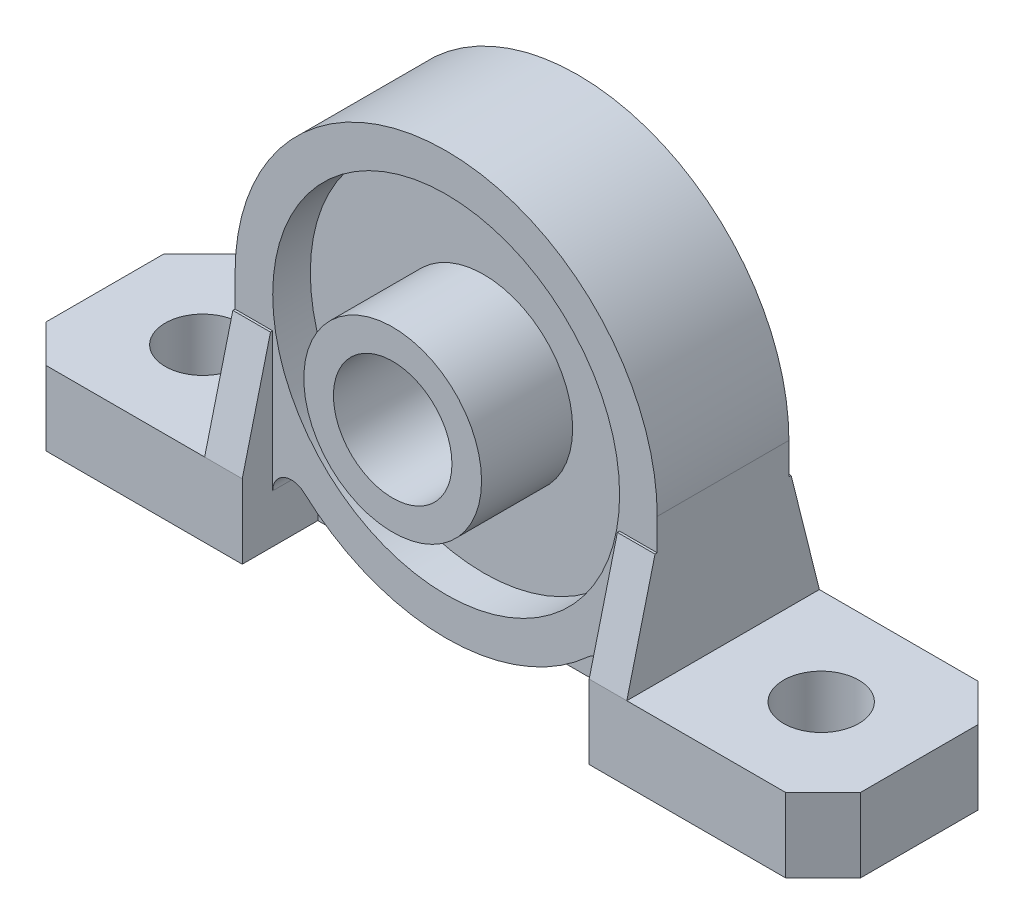
from build123d import *

# Parameters (mm, degrees)
SKETCH1_W                = 55
SKETCH1_H                = 13
BOSS_EXTRUDE1_DEPTH      = 29
CUT_EXTRUDE1_DEPTH       = 14
SKETCH3_OUTSIDE_W        = 69.704
SKETCH3_OUTSIDE_H        = 27.704
SKETCH3_OUTSIDE_W_2      = 28.5
SKETCH3_OUTSIDE_H_2      = 8.89
CUT_EXTRUDE2_DEPTH       = 25
SKETCH5_W                = 2.54
SKETCH5_H                = 7.62
BOSS_EXTRUDE2_DEPTH      = 6.5
BOSS_EXTRUDE2_DEPTH_BACK = 6.5
CHAMFER1_SIZE            = 1.905
CHAMFER1_SIZE2           = 7.62
CHAMFER1_PART_2_SIZE     = 1.905
CHAMFER1_PART_2_SIZE2    = 7.62
CHAMFER2_SIZE            = 7.62
CHAMFER2_SIZE2           = 1.905
CUT_EXTRUDE3_START       = -1.397
CUT_EXTRUDE3_DEPTH       = 6.1030001
CUT_EXTRUDE4_START       = -4.445
SKETCH7_W                = 23.42
SKETCH7_H                = 12.62
CUT_EXTRUDE4_DEPTH       = 3.0550001
SKETCH8_R                = 4
CUT_EXTRUDE5_DEPTH       = 7.5000001
CUT_EXTRUDE5_DEPTH_BACK  = 7.5000001
SKETCH9_R                = 11.71
CUT_EXTRUDE6_DEPTH       = 2.54
CHAMFER3_SIZE            = 2.54
SKETCH10_R               = 2.54
CUT_EXTRUDE7_DEPTH       = 6.0000001
SKETCH11_R               = 6
SKETCH11_R_2             = 4
BOSS_EXTRUDE3_DEPTH      = 6.15


with BuildPart() as part:
    # Sketch1 → Boss-Extrude1 (new body)
    with BuildSketch(Plane(origin=(0, 0, 0), x_dir=(1, 0, 0), z_dir=(0, 1, 0))):
        Rectangle(SKETCH1_W, SKETCH1_H)
    extrude(amount=BOSS_EXTRUDE1_DEPTH)

    # Sketch2 → Cut-Extrude1 (cut, through all)
    with BuildSketch(Plane.XY.offset(6.5)):
        with BuildLine():
            ThreePointArc((-14.25, 14.75), (-10.076271632, 24.826271632), (0, 29))
            Line((0, 29), (-27.5, 29))
            Line((-27.5, 29), (-27.5, 5))
            Line((-27.5, 5), (-14.25, 5))
            Line((-14.25, 5), (-14.25, 14.75))
        make_face()
        with BuildLine():
            Line((14.25, 5), (27.5, 5))
            Line((27.5, 5), (27.5, 29))
            Line((27.5, 29), (0, 29))
            ThreePointArc((0, 29), (10.076271632, 24.826271632), (14.25, 14.75))
            Line((14.25, 14.75), (14.25, 5))
        make_face()
    extrude(amount=-CUT_EXTRUDE1_DEPTH, mode=Mode.SUBTRACT)

    # Sketch3 outside → Cut-Extrude2 (cut, through all)
    with BuildSketch(Plane(origin=(0, 5, 0), x_dir=(1, 0, 0), z_dir=(0, 1, 0))):
        Rectangle(SKETCH3_OUTSIDE_W, SKETCH3_OUTSIDE_H)
        Rectangle(SKETCH3_OUTSIDE_W_2, SKETCH3_OUTSIDE_H_2, mode=Mode.SUBTRACT)
    extrude(amount=CUT_EXTRUDE2_DEPTH, mode=Mode.SUBTRACT)

    # Sketch5 → Boss-Extrude2 (add, two sides)
    with BuildSketch(Plane.XY) as boss_extrude2_sk:
        with Locations((12.98, 8.81)):
            Rectangle(SKETCH5_W, SKETCH5_H)
        with Locations((-12.98, 8.81)):
            Rectangle(SKETCH5_W, SKETCH5_H)
    extrude(amount=BOSS_EXTRUDE2_DEPTH)
    extrude(boss_extrude2_sk.sketch, amount=-BOSS_EXTRUDE2_DEPTH_BACK)

    # Chamfer1
    chamfer1_edges = [part.edges().sort_by_distance(p)[0] for p in [
        (12.98, 12.62, 6.5),
    ]]
    chamfer1_side = [part.faces().sort_by_distance(p)[0] for p in [
        (12.98, 12.62, 5.4725),
    ]]
    chamfer(chamfer1_edges, length=CHAMFER1_SIZE, length2=CHAMFER1_SIZE2, reference=chamfer1_side[0])

    # Chamfer1 part 2
    chamfer1_part_2_edges = [part.edges().sort_by_distance(p)[0] for p in [
        (-12.98, 12.62, 6.5),
    ]]
    chamfer1_part_2_side = [part.faces().sort_by_distance(p)[0] for p in [
        (-12.98, 12.62, 5.4725),
    ]]
    chamfer(chamfer1_part_2_edges, length=CHAMFER1_PART_2_SIZE, length2=CHAMFER1_PART_2_SIZE2, reference=chamfer1_part_2_side[0])

    # Chamfer2
    chamfer2_edges = [part.edges().sort_by_distance(p)[0] for p in [
        (-12.98, 12.62, -6.5),
        (12.98, 12.62, -6.5),
    ]]
    chamfer2_side = [part.faces().sort_by_distance(p)[0] for p in [
        (0, 3.27861046, -6.5),
    ]]
    chamfer(chamfer2_edges, length=CHAMFER2_SIZE, length2=CHAMFER2_SIZE2, reference=chamfer2_side[0])

    # Sketch6 → Cut-Extrude3 (cut, through all)
    with BuildSketch(Plane.XY.offset(CUT_EXTRUDE3_START)):
        with BuildLine():
            Line((11.71, 3.26623755), (11.71, 0))
            Line((11.71, 0), (-11.71, 0))
            Line((-11.71, 0), (-11.71, 3.26623755))
            ThreePointArc((-11.71, 3.26623755), (-10.953777074, 4.427673351), (-9.585695876, 4.205952648))
            ThreePointArc((-9.585695876, 4.205952648), (0, 0.5), (9.585695876, 4.205952648))
            ThreePointArc((9.585695876, 4.205952648), (10.953777074, 4.427673351), (11.71, 3.26623755))
        make_face()
    cut_extrude3 = extrude(amount=-CUT_EXTRUDE3_DEPTH, mode=Mode.SUBTRACT)

    # Sketch7 → Cut-Extrude4 (cut, through all)
    with BuildSketch(Plane.XY.offset(CUT_EXTRUDE4_START)):
        with Locations((0, 6.31)):
            Rectangle(SKETCH7_W, SKETCH7_H)
    cut_extrude4 = extrude(amount=-CUT_EXTRUDE4_DEPTH, mode=Mode.SUBTRACT)

    # Sketch8 → Cut-Extrude5 (cut, two sides)
    with BuildSketch(Plane.XY) as cut_extrude5_sk:
        with Locations((0, 14.5)):
            Circle(SKETCH8_R)
    extrude(amount=CUT_EXTRUDE5_DEPTH, mode=Mode.SUBTRACT)
    extrude(cut_extrude5_sk.sketch, amount=-CUT_EXTRUDE5_DEPTH_BACK, mode=Mode.SUBTRACT)

    # Sketch9 → Cut-Extrude6 (cut)
    with BuildSketch(Plane(origin=(0, 0, -4.445), x_dir=(-1, 0, 0), z_dir=(0, 0, -1))):
        with Locations((0, 14.75)):
            Circle(SKETCH9_R)
    cut_extrude6 = extrude(amount=-CUT_EXTRUDE6_DEPTH, mode=Mode.SUBTRACT)

    # Mirror1: Cut-Extrude3, Cut-Extrude4, Cut-Extrude6 across plane
    add(cut_extrude3.mirror(Plane.XY), mode=Mode.SUBTRACT)
    add(cut_extrude4.mirror(Plane.XY), mode=Mode.SUBTRACT)
    add(cut_extrude6.mirror(Plane.XY), mode=Mode.SUBTRACT)

    # Chamfer3
    chamfer3_edges = [part.edges().sort_by_distance(p)[0] for p in [
        (-27.5, 2.5, 6.5),
        (-27.5, 2.5, -6.5),
        (27.5, 2.5, 6.5),
        (27.5, 2.5, -6.5),
    ]]
    chamfer(chamfer3_edges, length=CHAMFER3_SIZE)

    # Sketch10 → Cut-Extrude7 (cut, through all)
    with BuildSketch(Plane(origin=(0, 5, 0), x_dir=(1, 0, 0), z_dir=(0, 1, 0))):
        with Locations((20.875, 0)):
            Circle(SKETCH10_R)
    cut_extrude7 = extrude(amount=-CUT_EXTRUDE7_DEPTH, mode=Mode.SUBTRACT)

    # Mirror2: Cut-Extrude7 across plane
    add(cut_extrude7.mirror(Plane(origin=(0, 0, 0), x_dir=(0, 0, 1), z_dir=(1, 0, 0))), mode=Mode.SUBTRACT)

    # Sketch11 → Boss-Extrude3 (add)
    with BuildSketch(Plane.XY.offset(1.905)):
        with Locations((0, 14.5)):
            Circle(SKETCH11_R)
        with Locations((0, 14.5)):
            Circle(SKETCH11_R_2, mode=Mode.SUBTRACT)
    extrude(amount=BOSS_EXTRUDE3_DEPTH)


solid = part.part
